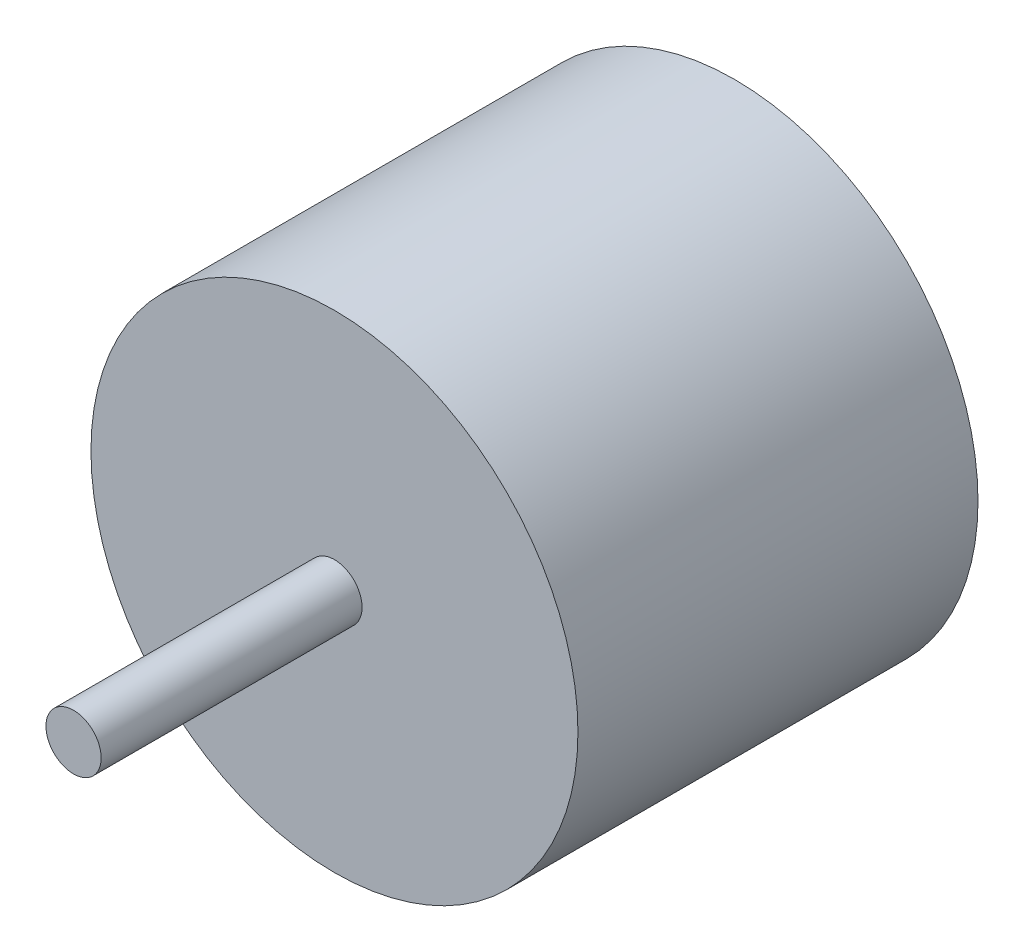
from build123d import *

# Parameters (mm, degrees)
SKETCH1_R           = 14
BOSS_EXTRUDE1_DEPTH = 23
SKETCH1_3_R         = 1.5875
BOSS_EXTRUDE2_DEPTH = 15


with BuildPart() as part:
    # Sketch1 → Boss-Extrude1 (new body)
    with BuildSketch(Plane.XY):
        Circle(SKETCH1_R)
    extrude(amount=-BOSS_EXTRUDE1_DEPTH)

    # Sketch1_3 → Boss-Extrude2 (add)
    with BuildSketch(Plane.XY):
        Circle(SKETCH1_3_R)
    extrude(amount=BOSS_EXTRUDE2_DEPTH)


solid = part.part
